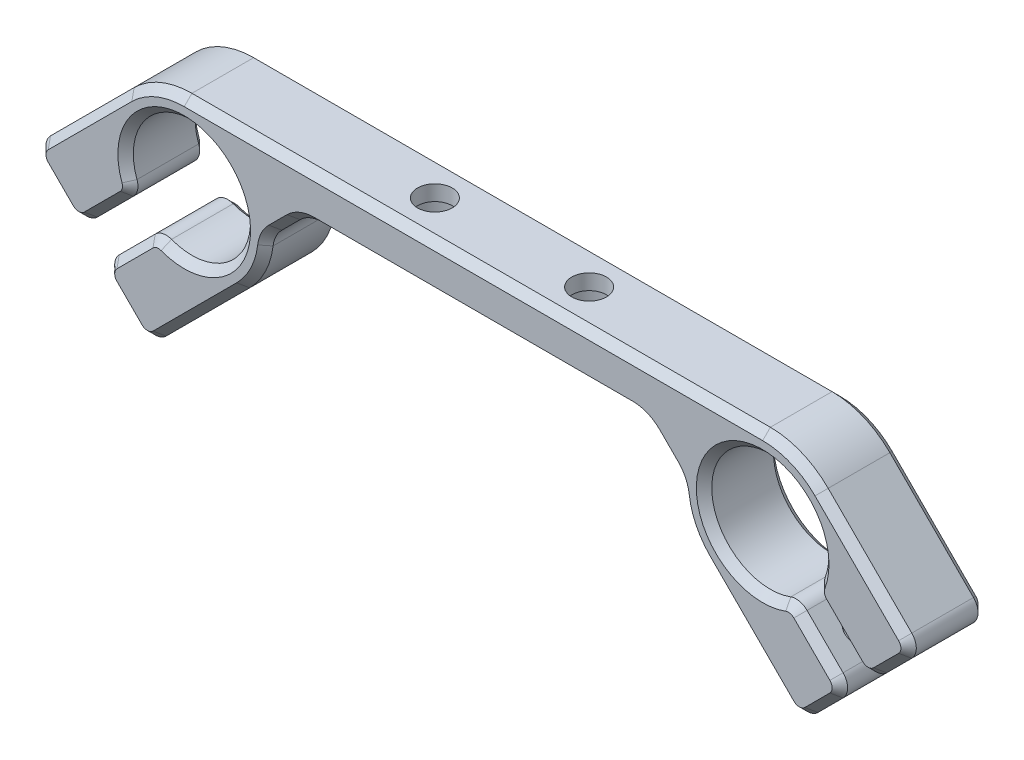
from build123d import *

# Parameters (mm, degrees)
EXTRUDE_1_DEPTH             = 10
M4X0_71_D                   = 3.3
M4X0_71_DEPTH               = 19
M4X0_71_TIP                 = 0.991420021
M4X0_72_D                   = 3.3
M4X0_72_DEPTH               = 19
M4X0_72_TIP                 = 0.991420021
FILLET_1_R                  = 2
FILLET_2_R                  = 4
CHAMFER_1_SIZE              = 1
HOLE_WIZARD_M41_D           = 4.5
HOLE_WIZARD_M41_CBORE_D     = 8
HOLE_WIZARD_M41_CBORE_DEPTH = 4


with BuildPart() as part:
    # Эскиз1 → Бобышка-Вытянуть1 (new body)
    with BuildSketch(Plane.XY):
        with BuildLine():
            Line((-44.995331881, 7.495331881), (-57.250992251, -4.76032849))
            Line((-57.250992251, -4.76032849), (-51.169873933, -10.841446808))
            Line((-51.169873933, -10.841446808), (-44.098806121, -3.770378996))
            ThreePointArc((-44.098806121, -3.770378996), (-32.125988463, 5.374011537), (-41.270378996, -6.598806121))
            Line((-41.270378996, -6.598806121), (-48.341446808, -13.669873933))
            Line((-48.341446808, -13.669873933), (-42.26032849, -19.750992251))
            Line((-42.26032849, -19.750992251), (-30.004668119, -7.495331881))
            ThreePointArc((-30.004668119, -7.495331881), (-27.706876955, -4.056444383), (-26.9, 0))
            Line((-26.9, 0), (-22.3, 4.6))
            Line((-22.3, 4.6), (22.3, 4.6))
            Line((22.3, 4.6), (26.9, 0))
            ThreePointArc((26.9, 0), (27.706876955, -4.056444383), (30.004668119, -7.495331881))
            Line((30.004668119, -7.495331881), (42.26032849, -19.750992251))
            Line((42.26032849, -19.750992251), (48.341446808, -13.669873933))
            Line((48.341446808, -13.669873933), (41.270378996, -6.598806121))
            ThreePointArc((41.270378996, -6.598806121), (32.125988463, 5.374011537), (44.098806121, -3.770378996))
            Line((44.098806121, -3.770378996), (51.169873933, -10.841446808))
            Line((51.169873933, -10.841446808), (57.250992251, -4.76032849))
            Line((57.250992251, -4.76032849), (44.995331881, 7.495331881))
            ThreePointArc((44.995331881, 7.495331881), (41.556444383, 9.793123045), (37.5, 10.6))
            Line((37.5, 10.6), (-37.5, 10.6))
            ThreePointArc((-37.5, 10.6), (-41.556444383, 9.793123045), (-44.995331881, 7.495331881))
        make_face()
    extrude(amount=EXTRUDE_1_DEPTH)

    # Отверстие обработанное метчиком M4x0.71
    with Locations(Plane(origin=(11.254668119, 11.254668119, 0), x_dir=(0, 0, 1), z_dir=(-0.707106781, -0.707106781, 0))):
        with Locations((5, -38.848625406)):
            Hole(M4X0_71_D / 2, depth=M4X0_71_DEPTH)
            with Locations((0, 0, -(M4X0_71_DEPTH + M4X0_71_TIP / 2))):  # 118° drill point
                Cone(0, M4X0_71_D / 2, M4X0_71_TIP, mode=Mode.SUBTRACT)

    # Отверстие обработанное метчиком M4x0.72
    with Locations(Plane(origin=(-11.254668119, 11.254668119, 0), x_dir=(0, 0, -1), z_dir=(0.707106781, -0.707106781, 0))):
        with Locations((-5, -38.848625406)):
            Hole(M4X0_72_D / 2, depth=M4X0_72_DEPTH)
            with Locations((0, 0, -(M4X0_72_DEPTH + M4X0_72_TIP / 2))):  # 118° drill point
                Cone(0, M4X0_72_D / 2, M4X0_72_TIP, mode=Mode.SUBTRACT)

    # Скругление1
    fillet_1_edges = [part.edges().sort_by_distance(p)[0] for p in [
        (-42.26032849, -19.750992251, 5),
        (-48.341446808, -13.669873933, 5),
        (-41.270378996, -6.598806121, 5),
        (-44.098806121, -3.770378996, 5),
        (-51.169873933, -10.841446808, 5),
        (-57.250992251, -4.76032849, 5),
        (57.250992251, -4.76032849, 5),
        (51.169873933, -10.841446808, 5),
        (44.098806121, -3.770378996, 5),
        (41.270378996, -6.598806121, 5),
        (48.341446808, -13.669873933, 5),
        (42.26032849, -19.750992251, 5),
    ]]
    fillet(fillet_1_edges, radius=FILLET_1_R)

    # Скругление2
    fillet_2_edges = [part.edges().sort_by_distance(p)[0] for p in [
        (26.9, 0, 5),
        (22.3, 4.6, 5),
        (-22.3, 4.6, 5),
        (-26.9, 0, 5),
    ]]
    fillet(fillet_2_edges, radius=FILLET_2_R)

    # Фаска1
    chamfer_1_edges = [part.edges().sort_by_distance(p)[0] for p in [
        (-41.268947779, -7.045325886, 10),
        (-44.545325886, -3.768947779, 10),
        (41.268947779, -7.045325886, 10),
        (44.545325886, -3.768947779, 10),
        (47.513019683, -13.669873933, 10),
        (42.26032849, -18.922565126, 10),
        (51.169873933, -10.013019683, 10),
        (56.422565126, -4.76032849, 10),
        (-24.653465253, 2.246534747, 0),
        (-24.653465253, 2.246534747, 10),
        (0, 4.6, 0),
        (0, 4.6, 10),
        (27.970298296, -4.641636073, 0),
        (27.970298296, -4.641636073, 10),
        (24.653465253, 2.246534747, 0),
        (24.653465253, 2.246534747, 10),
        (-26.603044357, -0.012223974, 0),
        (-26.603044357, -0.012223974, 10),
        (-22.17387948, 4.29551813, 0),
        (-22.17387948, 4.29551813, 10),
        (26.603044357, -0.012223974, 0),
        (26.603044357, -0.012223974, 10),
        (22.17387948, 4.29551813, 0),
        (22.17387948, 4.29551813, 10),
        (35.425391524, -12.916055285, 10),
        (-50.416055285, 2.074608476, 0),
        (-41.556444383, 9.793123045, 0),
        (0, 10.6, 0),
        (41.556444383, 9.793123045, 0),
        (35.425391524, -12.916055285, 0),
        (-27.970298296, -4.641636073, 0),
        (-27.970298296, -4.641636073, 10),
        (41.556444383, 9.793123045, 10),
        (0, 10.6, 10),
        (-41.556444383, 9.793123045, 10),
        (-50.416055285, 2.074608476, 10),
        (50.416055285, 2.074608476, 0),
        (50.416055285, 2.074608476, 10),
        (-35.425391524, -12.916055285, 0),
        (-45.300887649, -16.710433092, 0),
        (-44.591959566, -9.920386691, 0),
        (-32.125988463, 5.374011537, 0),
        (-47.420386691, -7.091959566, 0),
        (-54.210433092, -7.800887649, 0),
        (54.210433092, -7.800887649, 0),
        (47.420386691, -7.091959566, 0),
        (32.125988463, 5.374011537, 0),
        (44.591959566, -9.920386691, 0),
        (45.300887649, -16.710433092, 0),
        (-42.26032849, -18.922565126, 0),
        (-47.513019683, -13.669873933, 0),
        (-51.169873933, -10.013019683, 0),
        (-56.422565126, -4.76032849, 0),
        (-41.268947779, -7.045325886, 0),
        (-44.545325886, -3.768947779, 0),
        (41.268947779, -7.045325886, 0),
        (44.545325886, -3.768947779, 0),
        (47.513019683, -13.669873933, 0),
        (42.26032849, -18.922565126, 0),
        (51.169873933, -10.013019683, 0),
        (56.422565126, -4.76032849, 0),
        (54.210433092, -7.800887649, 10),
        (45.300887649, -16.710433092, 10),
        (44.591959566, -9.920386691, 10),
        (32.125988463, 5.374011537, 10),
        (47.420386691, -7.091959566, 10),
        (-54.210433092, -7.800887649, 10),
        (-47.420386691, -7.091959566, 10),
        (-32.125988463, 5.374011537, 10),
        (-44.591959566, -9.920386691, 10),
        (-45.300887649, -16.710433092, 10),
        (-35.425391524, -12.916055285, 10),
        (-42.26032849, -18.922565126, 10),
        (-47.513019683, -13.669873933, 10),
        (-51.169873933, -10.013019683, 10),
        (-56.422565126, -4.76032849, 10),
    ]]
    chamfer(chamfer_1_edges, length=CHAMFER_1_SIZE)

    # Цековка для винта с внутренним шестигранником M41 (through all)
    with Locations(Plane(origin=(0, 4.6, 0), x_dir=(-1, 0, 0), z_dir=(0, -1, 0))):
        with Locations((10, -5), (-10, -5)):
            CounterBoreHole(HOLE_WIZARD_M41_D / 2, HOLE_WIZARD_M41_CBORE_D / 2, HOLE_WIZARD_M41_CBORE_DEPTH)


solid = part.part
